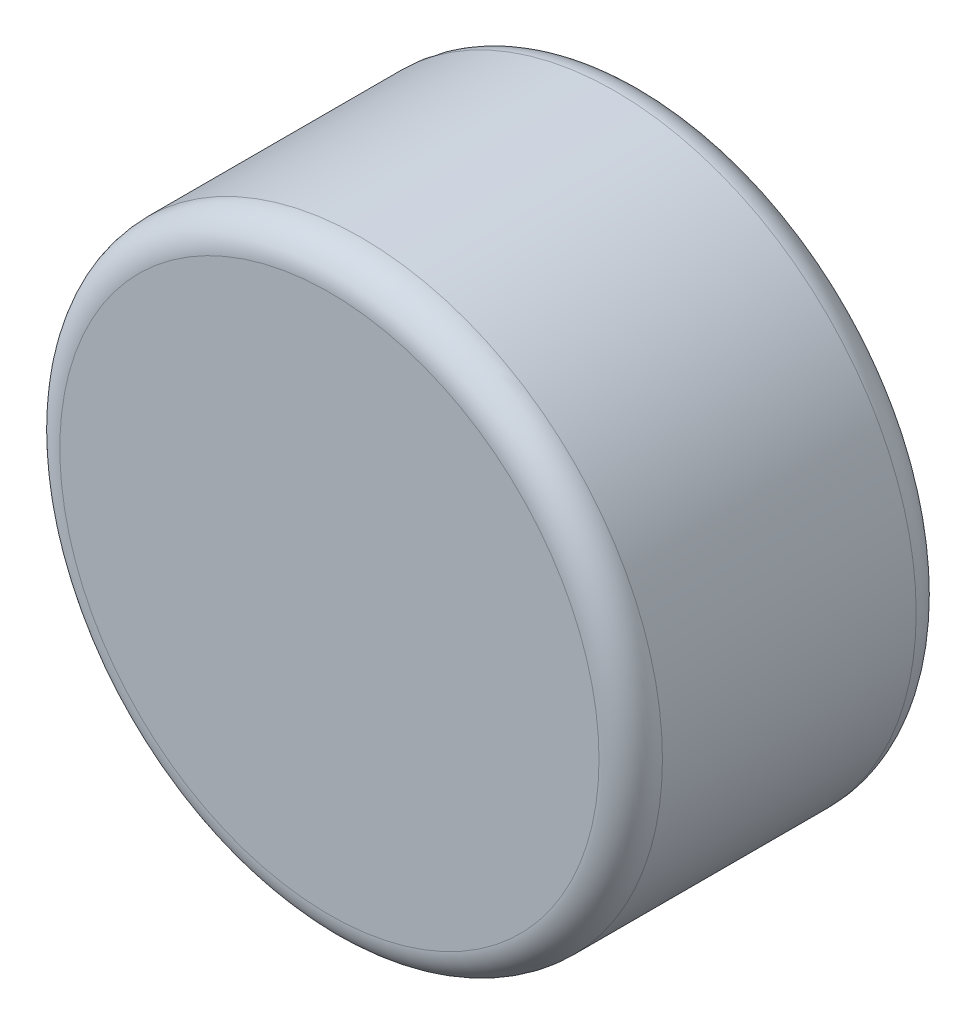
from build123d import *

# Parameters (mm, degrees)
SKETCH1_R           = 47.5
BOSS_EXTRUDE1_DEPTH = 50
FILLET1_R           = 5


with BuildPart() as part:
    # Sketch1 → Boss-Extrude1 (new body)
    with BuildSketch(Plane.XY):
        Circle(SKETCH1_R)
    extrude(amount=BOSS_EXTRUDE1_DEPTH)

    # Fillet1
    fillet1_edges = [part.edges().sort_by_distance(p)[0] for p in [
        (-47.5, 0, 0),
        (-47.5, 0, 50),
    ]]
    fillet(fillet1_edges, radius=FILLET1_R)


solid = part.part
